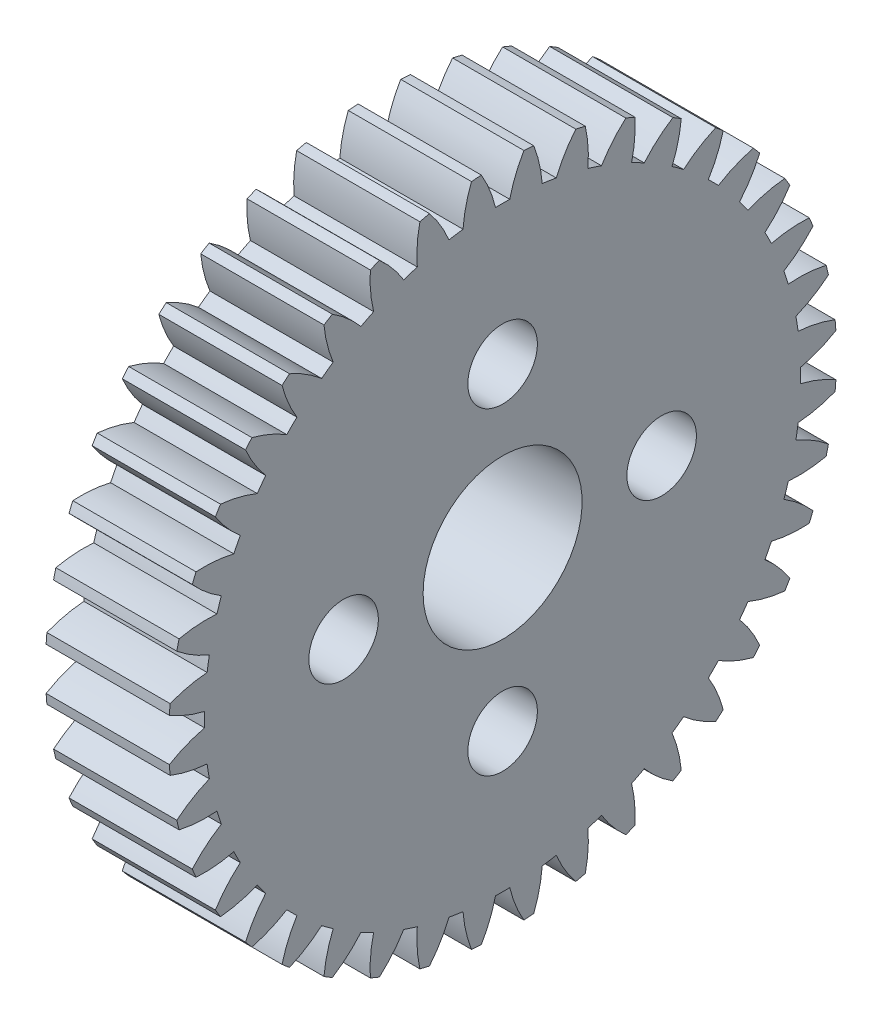
from build123d import *

# Parameters (mm, degrees)
BASPROSKE_W                = 6.2
BASPROSKE_H                = 16.8
TOOTHCUT_DEPTH             = 25.554429336
TEETHCUTS_COUNT            = 40
TEETHCUTS_ANGLE            = 351
BORSKE_R                   = 4
BORE_DEPTH                 = 50.0000508
F_3_5_3_5_DIAMETER_HOLE1_D = 3.5


with BuildPart() as part:
    # BasProSke → Base-Revolve (revolve)
    with BuildSketch(Plane(origin=(0, 0, 0), x_dir=(1, 0, 0), z_dir=(0, 1, 0)), mode=Mode.PRIVATE) as base_revolve_sk:
        with Locations((3.1, 8.4)):
            Rectangle(BASPROSKE_W, BASPROSKE_H)
    revolve(base_revolve_sk.sketch.rotate(Axis((-10, 0, 0), (1, 0, 0)), 180), axis=Axis((-10, 0, 0), (1, 0, 0)))

    # TooCutSke → ToothCut (cut, through all)
    with BuildSketch(Plane(origin=(0, 0, 0), x_dir=(0, 0, -1), z_dir=(1, 0, 0))):
        with BuildLine():
            ThreePointArc((0.358234928, 14.994721362), (0, 14.999), (-0.358234928, 14.994721362))
            ThreePointArc((-0.358234928, 14.994721362), (-0.653764873, 15.920217236), (-1.085976921, 16.790316831))
            ThreePointArc((-1.085976921, 16.790316831), (0, 16.8254), (1.085976921, 16.790316831))
            ThreePointArc((1.085976921, 16.790316831), (0.653764873, 15.920217236), (0.358234928, 14.994721362))
        make_face()
    toothcut = extrude(amount=TOOTHCUT_DEPTH, mode=Mode.SUBTRACT)

    # TeethCuts: ToothCut ×40 about axis
    teethcuts_axis = Axis((-10, 0, 0), (1, 0, 0))
    for i in range(1, TEETHCUTS_COUNT):
        add(toothcut.rotate(teethcuts_axis, i * TEETHCUTS_ANGLE / (TEETHCUTS_COUNT - 1)), mode=Mode.SUBTRACT)

    # BorSke → Bore (cut, symmetric)
    with BuildSketch(Plane(origin=(0, 0, 0), x_dir=(0, 0, -1), z_dir=(1, 0, 0))):
        with Locations(Location((0, 0, 0), (0, 0, 180))):
            Circle(BORSKE_R)
    extrude(amount=BORE_DEPTH, both=True, mode=Mode.SUBTRACT)

    # Ø3.5 (3.5) Diameter Hole1 (through all)
    with Locations(Plane(origin=(6.2, 0, 0), x_dir=(0, 0, -1), z_dir=(1, 0, 0))):
        with Locations((0, 8), (8, 0), (0, -8), (-8, 0)):
            Hole(F_3_5_3_5_DIAMETER_HOLE1_D / 2)


solid = part.part
